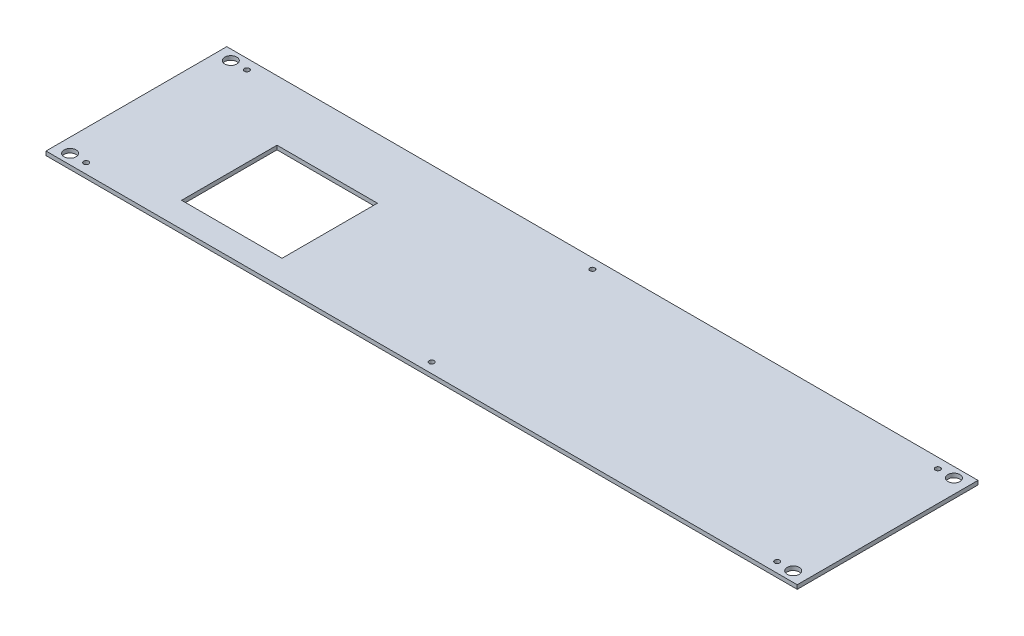
from build123d import *

# Parameters (mm, degrees)
SKETCH1_W           = 748
SKETCH1_H           = 180
SKETCH1_R           = 2.5
SKETCH1_R_2         = 6
SKETCH1_W_2         = 100
SKETCH1_H_2         = 95
BOSS_EXTRUDE1_DEPTH = 4


with BuildPart() as part:
    # Sketch1 → Boss-Extrude1 (new body)
    with BuildSketch(Plane(origin=(0, 0, 0), x_dir=(1, 0, 0), z_dir=(0, 1, 0))):
        Rectangle(SKETCH1_W, SKETCH1_H)
        with Locations((-344, 80)):
            Circle(SKETCH1_R, mode=Mode.SUBTRACT)
        with Locations((0, 80)):
            Circle(SKETCH1_R, mode=Mode.SUBTRACT)
        with Locations((344, 80)):
            Circle(SKETCH1_R, mode=Mode.SUBTRACT)
        with Locations((-344, -80)):
            Circle(SKETCH1_R, mode=Mode.SUBTRACT)
        with Locations((0, -80)):
            Circle(SKETCH1_R, mode=Mode.SUBTRACT)
        with Locations((344, -80)):
            Circle(SKETCH1_R, mode=Mode.SUBTRACT)
        with Locations((-360, 80)):
            Circle(SKETCH1_R_2, mode=Mode.SUBTRACT)
        with Locations((-360, -80)):
            Circle(SKETCH1_R_2, mode=Mode.SUBTRACT)
        with Locations((360, -80)):
            Circle(SKETCH1_R_2, mode=Mode.SUBTRACT)
        with Locations((360, 80)):
            Circle(SKETCH1_R_2, mode=Mode.SUBTRACT)
        with Locations((-214, -17.5)):
            Rectangle(SKETCH1_W_2, SKETCH1_H_2, mode=Mode.SUBTRACT)
    extrude(amount=BOSS_EXTRUDE1_DEPTH)


solid = part.part
